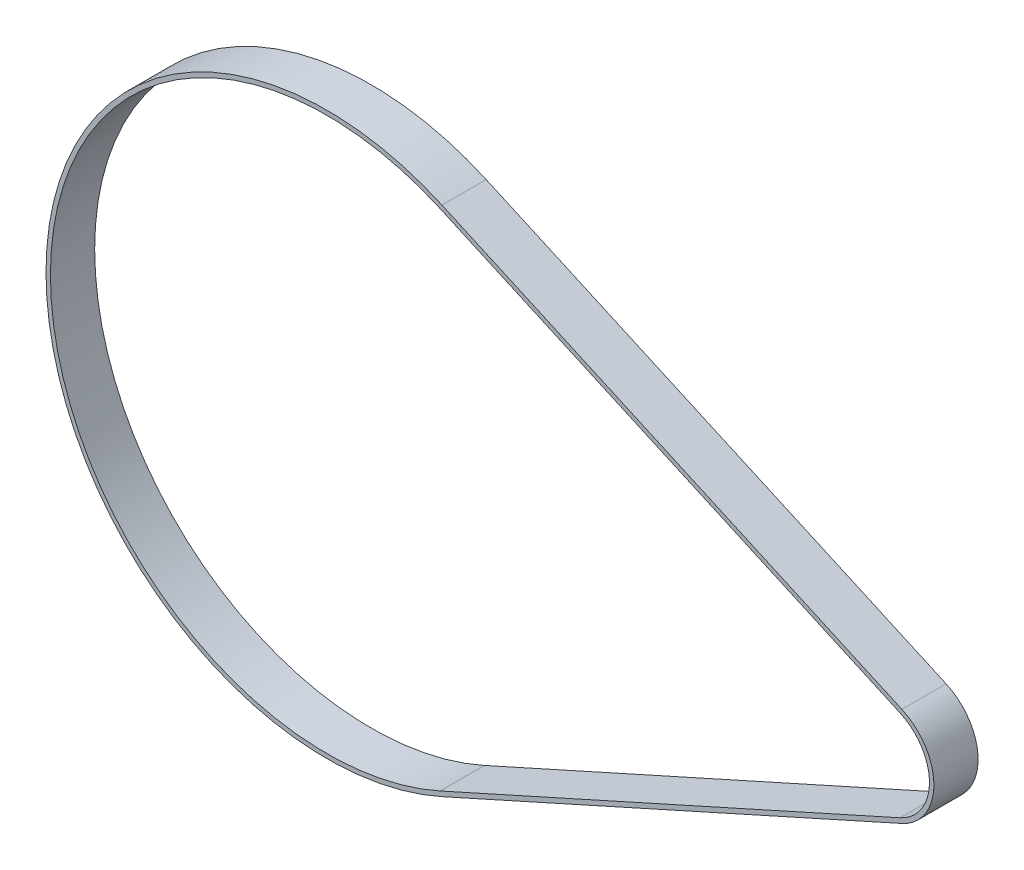
from build123d import *

# Parameters (mm, degrees)
EXTRUDE_THIN1_DEPTH = 10


with BuildPart() as part:
    # Sketch2 → Extrude-Thin1 (new, symmetric)
    with BuildSketch(Plane.XY):
        with BuildLine():
            Line((260.045, -22.346095296), (52.07, -115.834861333))
            ThreePointArc((52.07, -115.834861333), (-127, 0), (52.07, 115.834861333))
            Line((52.07, 115.834861333), (260.045, 22.346095296))
            ThreePointArc((260.045, 22.346095296), (274.5, 0), (260.045, -22.346095296))
        make_face()
        with BuildLine():
            Line((259.225, -20.521924252), (51.25, -114.010690288))
            ThreePointArc((51.25, -114.010690288), (-125, 0), (51.25, 114.010690288))
            Line((51.25, 114.010690288), (259.225, 20.521924252))
            ThreePointArc((259.225, 20.521924252), (272.5, 0), (259.225, -20.521924252))
        make_face(mode=Mode.SUBTRACT)
    extrude(amount=EXTRUDE_THIN1_DEPTH, both=True)


solid = part.part
